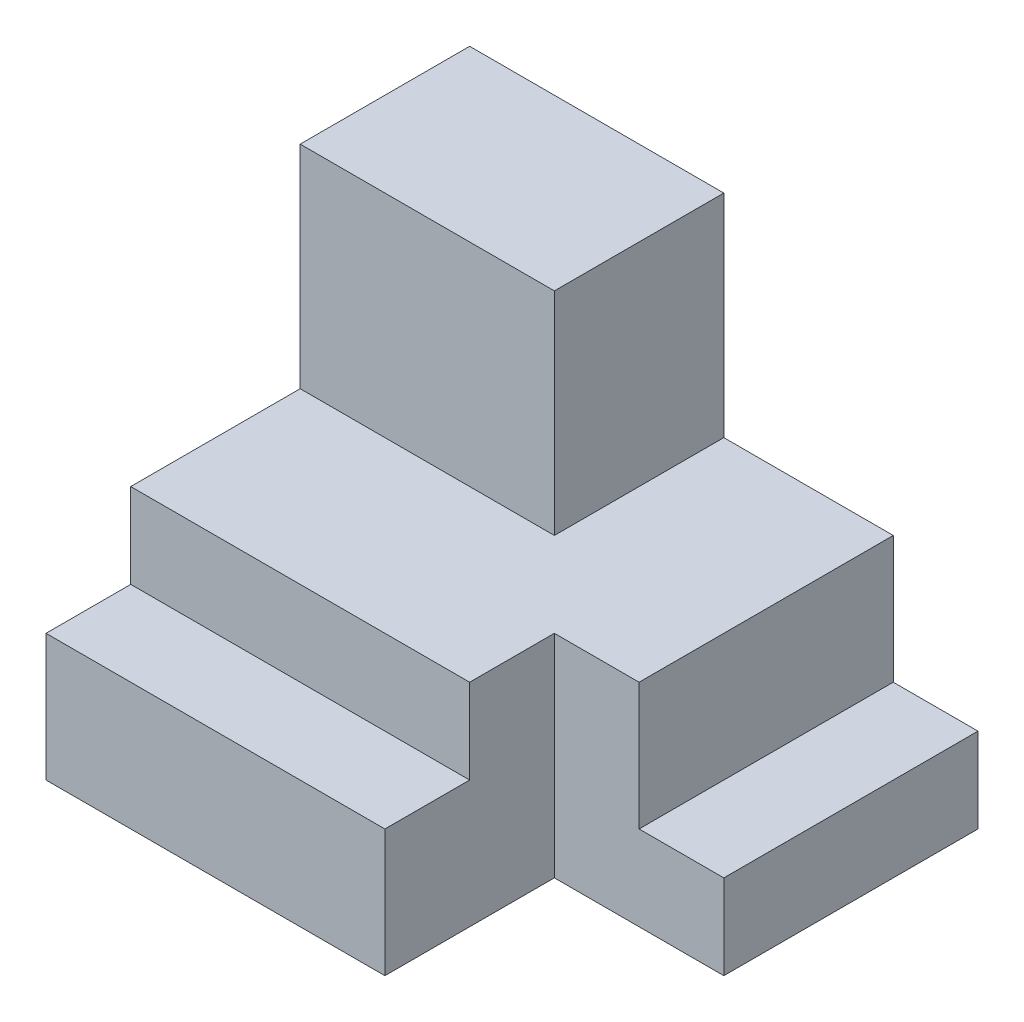
from build123d import *

# Parameters (mm, degrees)
BOSS_EXTRUDE1_DEPTH = 31.75
SKETCH3_W           = 12.7
SKETCH3_H           = 38.1
CUT_EXTRUDE3_DEPTH  = 19.05
SKETCH6_W           = 50.8
SKETCH6_H           = 12.7
CUT_EXTRUDE5_DEPTH  = 44.45
SKETCH7_W           = 50.8
SKETCH7_H           = 19.05
BOSS_EXTRUDE2_DEPTH = 12.7
SKETCH8_W           = 38.1
SKETCH8_H           = 25.4
BOSS_EXTRUDE3_DEPTH = 31.75


with BuildPart() as part:
    # Sketch1 → Boss-Extrude1 (new body)
    with BuildSketch(Plane(origin=(0, 0, 0), x_dir=(1, 0, 0), z_dir=(0, 1, 0))):
        Polygon((0, 0), (50.8, 0), (50.8, 25.4), (76.2, 25.4), (76.2, 63.5), (0, 63.5), align=None)
    extrude(amount=BOSS_EXTRUDE1_DEPTH)

    # Sketch3 → Cut-Extrude3 (cut)
    with BuildSketch(Plane(origin=(0, 31.75, 0), x_dir=(1, 0, 0), z_dir=(0, 1, 0))):
        with Locations((69.85, 44.45)):
            Rectangle(SKETCH3_W, SKETCH3_H)
    extrude(amount=-CUT_EXTRUDE3_DEPTH, mode=Mode.SUBTRACT)

    # Sketch6 → Cut-Extrude5 (cut)
    with BuildSketch(Plane.XZ):
        with Locations((25.4, -6.35)):
            Rectangle(SKETCH6_W, SKETCH6_H)
    extrude(amount=-CUT_EXTRUDE5_DEPTH, mode=Mode.SUBTRACT)

    # Sketch7 → Boss-Extrude2 (add)
    with BuildSketch(Plane.XY.offset(-12.7)):
        with Locations((25.4, 9.525)):
            Rectangle(SKETCH7_W, SKETCH7_H)
    extrude(amount=BOSS_EXTRUDE2_DEPTH)

    # Sketch8 → Boss-Extrude3 (add)
    with BuildSketch(Plane(origin=(0, 31.75, 0), x_dir=(1, 0, 0), z_dir=(0, 1, 0))):
        with Locations((19.05, 50.8)):
            Rectangle(SKETCH8_W, SKETCH8_H)
    extrude(amount=BOSS_EXTRUDE3_DEPTH)


solid = part.part
